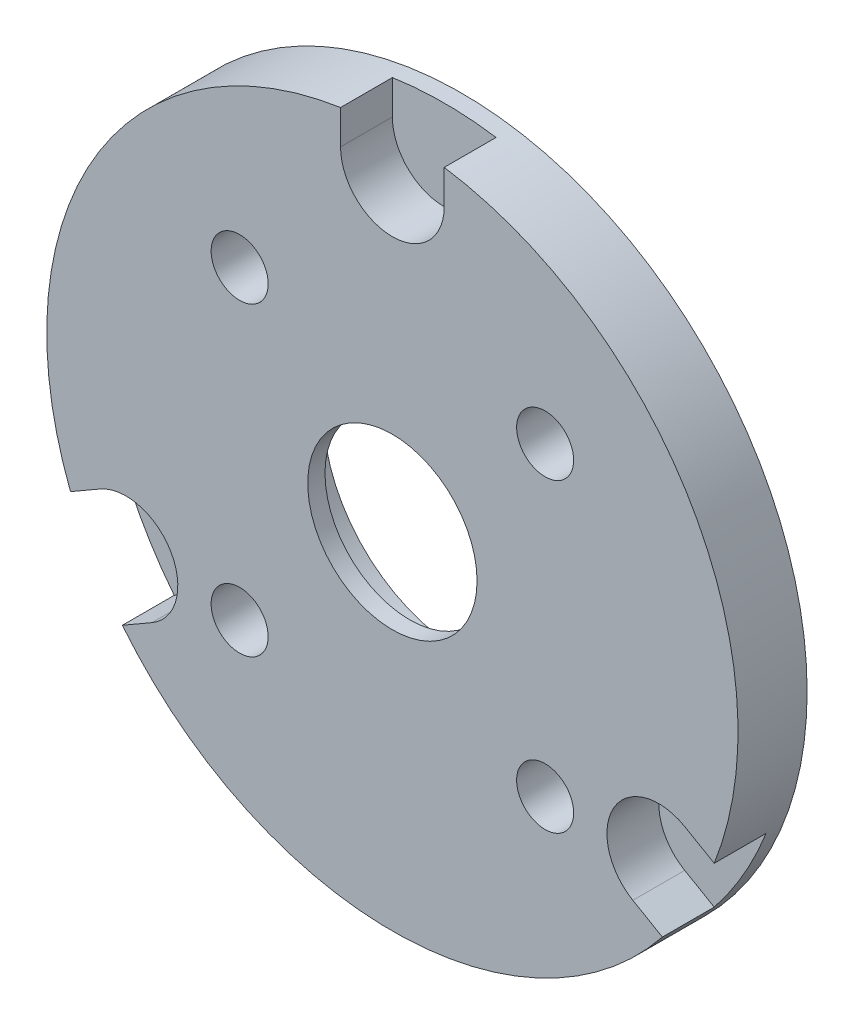
from build123d import *

# Parameters (mm, degrees)
SKETCH1_R             = 20
BOSS_EXTRUDE1_DEPTH   = 4
CUT_EXTRUDE1_DEPTH    = 3
M4X0_7_TAPPED_HOLE1_D = 3.3
SKETCH5_R             = 4.9
CUT_EXTRUDE2_DEPTH    = 5
SKETCH6_R             = 8
CUT_EXTRUDE3_DEPTH    = 3


with BuildPart() as part:
    # Sketch1 → Boss-Extrude1 (new body)
    with BuildSketch(Plane.XY):
        Circle(SKETCH1_R)
    extrude(amount=BOSS_EXTRUDE1_DEPTH)

    # Sketch2 → Cut-Extrude1 (cut)
    with BuildSketch(Plane.XY.offset(4)):
        with BuildLine():
            Line((-3, 17.8), (-3, 25))
            Line((-3, 25), (3, 25))
            Line((3, 25), (3, 17.8))
            ThreePointArc((3, 17.8), (0, 14.8), (-3, 17.8))
        make_face()
        with BuildLine():
            Line((16.915252187, -6.301923789), (23.150635095, -9.901923789))
            Line((23.150635095, -9.901923789), (20.150635095, -15.098076211))
            Line((20.150635095, -15.098076211), (13.915252187, -11.498076211))
            ThreePointArc((13.915252187, -11.498076211), (12.817175976, -7.4), (16.915252187, -6.301923789))
        make_face()
        with BuildLine():
            Line((-13.915252187, -11.498076211), (-20.150635095, -15.098076211))
            Line((-20.150635095, -15.098076211), (-23.150635095, -9.901923789))
            Line((-23.150635095, -9.901923789), (-16.915252187, -6.301923789))
            ThreePointArc((-16.915252187, -6.301923789), (-12.817175976, -7.4), (-13.915252187, -11.498076211))
        make_face()
    extrude(amount=-CUT_EXTRUDE1_DEPTH, mode=Mode.SUBTRACT)

    # M4x0.7 Tapped Hole1 (through all)
    with Locations(Plane.XY.offset(4)):
        with Locations((-8.838834765, 8.838834765), (8.838834765, 8.838834765), (8.838834765, -8.838834765), (-8.838834765, -8.838834765)):
            Hole(M4X0_7_TAPPED_HOLE1_D / 2)

    # Sketch5 → Cut-Extrude2 (cut, through all)
    with BuildSketch(Plane.XY.offset(4)):
        Circle(SKETCH5_R)
    extrude(amount=-CUT_EXTRUDE2_DEPTH, mode=Mode.SUBTRACT)

    # Sketch6 → Cut-Extrude3 (cut)
    with BuildSketch(Plane(origin=(0, 0, 0), x_dir=(-1, 0, 0), z_dir=(0, 0, -1))):
        Circle(SKETCH6_R)
    extrude(amount=-CUT_EXTRUDE3_DEPTH, mode=Mode.SUBTRACT)


solid = part.part
